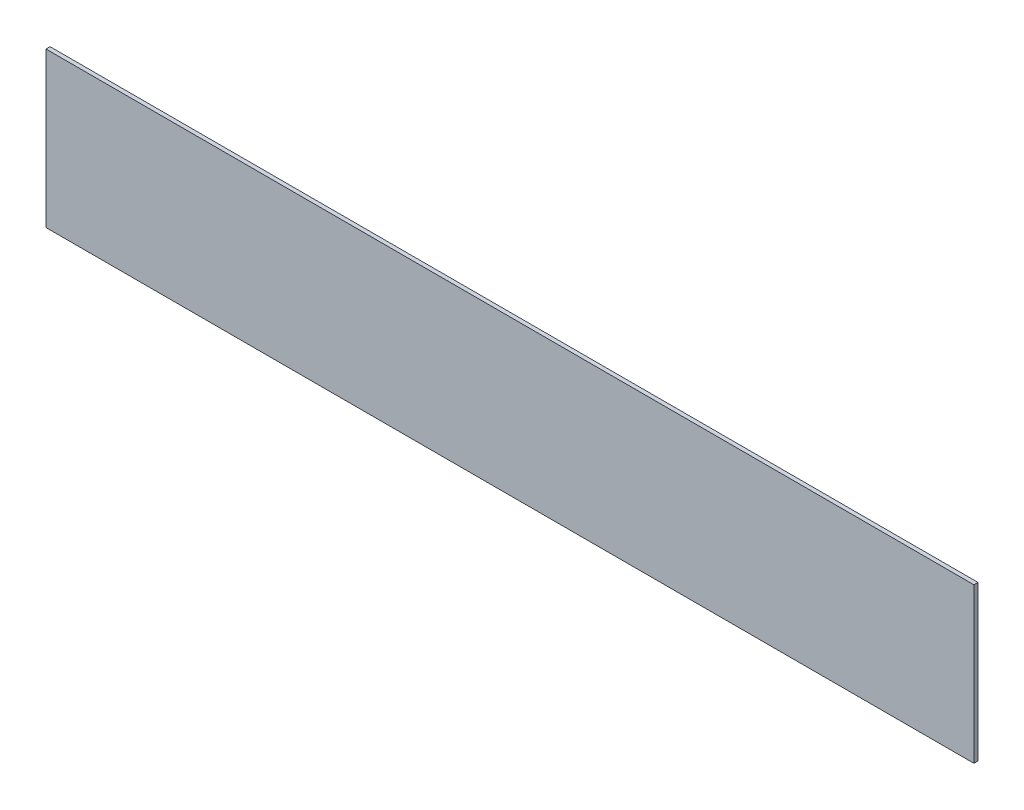
from build123d import *

# Parameters (mm, degrees)
SKETCH_1_W      = 457.2
SKETCH_1_H      = 76.2
EXTRUDE_1_DEPTH = 2


with BuildPart() as part:
    # Эскиз1 → Бобышка-Вытянуть1 (new body)
    with BuildSketch(Plane.XY):
        Rectangle(SKETCH_1_W, SKETCH_1_H)
    extrude(amount=EXTRUDE_1_DEPTH)


solid = part.part
